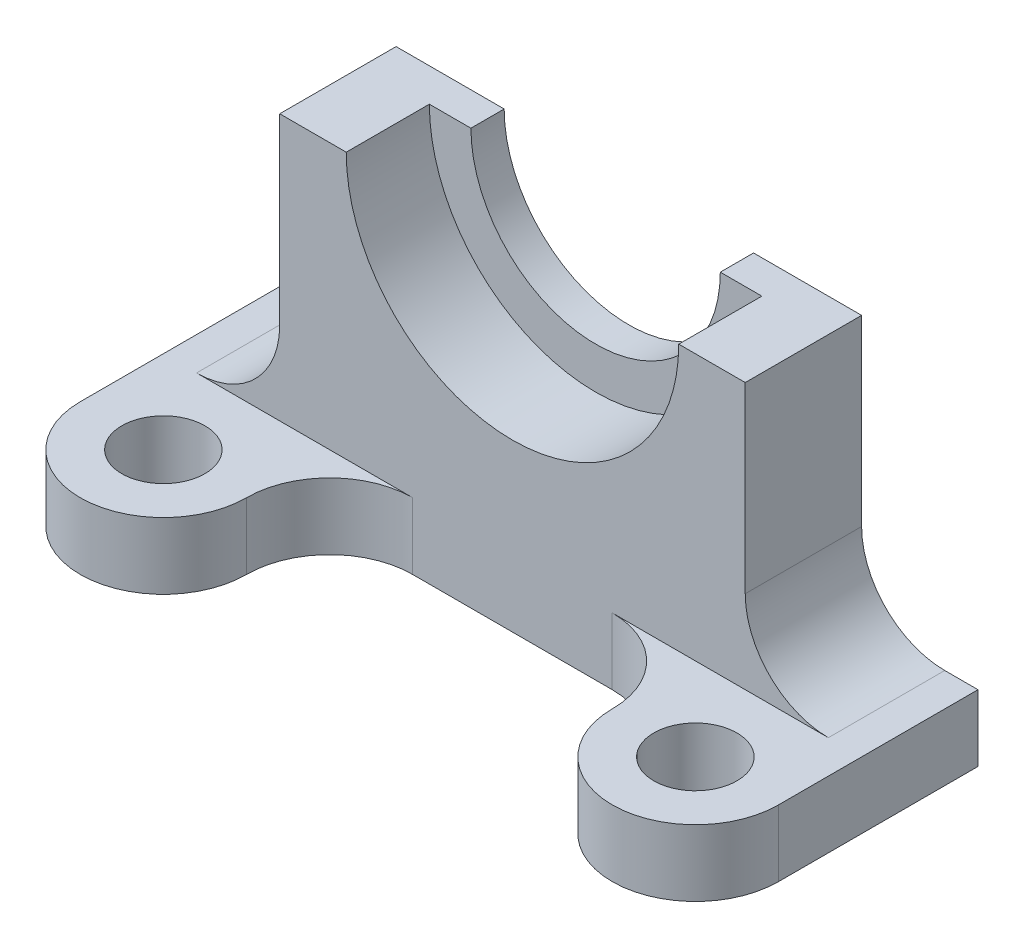
from build123d import *

# Parameters (mm, degrees)
SKETCH2_R           = 15.875
BOSS_EXTRUDE1_DEPTH = 25.4
BOSS_EXTRUDE2_DEPTH = 44.45
BOSS_EXTRUDE3_DEPTH = 12.7


with BuildPart() as part:
    # Sketch2 → Boss-Extrude1 (new body)
    with BuildSketch(Plane(origin=(0, 0, 0), x_dir=(1, 0, 0), z_dir=(0, 1, 0))):
        with BuildLine():
            Line((-133.35, 0), (133.35, 0))
            Line((133.35, 0), (133.35, -76.2))
            ThreePointArc((133.35, -76.2), (101.6, -107.95), (69.85, -76.2))
            ThreePointArc((69.85, -76.2), (60.550640303, -53.749359697), (38.1, -44.45))
            Line((38.1, -44.45), (-38.1, -44.45))
            ThreePointArc((-38.1, -44.45), (-60.550640303, -53.749359697), (-69.85, -76.2))
            ThreePointArc((-69.85, -76.2), (-101.6, -107.95), (-133.35, -76.2))
            Line((-133.35, -76.2), (-133.35, 0))
        make_face()
        with Locations((101.6, -76.2)):
            Circle(SKETCH2_R, mode=Mode.SUBTRACT)
        with Locations((-101.6, -76.2)):
            Circle(SKETCH2_R, mode=Mode.SUBTRACT)
    extrude(amount=BOSS_EXTRUDE1_DEPTH)

    # Sketch3 → Boss-Extrude2 (add)
    with BuildSketch(Plane(origin=(0, 0, 0), x_dir=(-1, 0, 0), z_dir=(0, 0, -1))):
        with BuildLine():
            ThreePointArc((63.5, 127), (0, 63.5), (-63.5, 127))
            Line((-63.5, 127), (-88.9, 127))
            Line((-88.9, 127), (-88.9, 57.15))
            ThreePointArc((-88.9, 57.15), (-98.199359697, 34.699359697), (-120.65, 25.4))
            Line((-120.65, 25.4), (0, 25.4))
            Line((0, 25.4), (120.65, 25.4))
            ThreePointArc((120.65, 25.4), (98.199359697, 34.699359697), (88.9, 57.15))
            Line((88.9, 57.15), (88.9, 127))
            Line((88.9, 127), (63.5, 127))
        make_face()
    extrude(amount=-BOSS_EXTRUDE2_DEPTH)

    # Sketch4 → Boss-Extrude3 (add)
    with BuildSketch(Plane(origin=(0, 0, 0), x_dir=(-1, 0, 0), z_dir=(0, 0, -1))):
        with BuildLine():
            Line((-47.625, 127), (-63.5, 127))
            ThreePointArc((-63.5, 127), (0, 63.5), (63.5, 127))
            Line((63.5, 127), (47.625, 127))
            ThreePointArc((47.625, 127), (0, 79.375), (-47.625, 127))
        make_face()
    extrude(amount=-BOSS_EXTRUDE3_DEPTH)


solid = part.part
